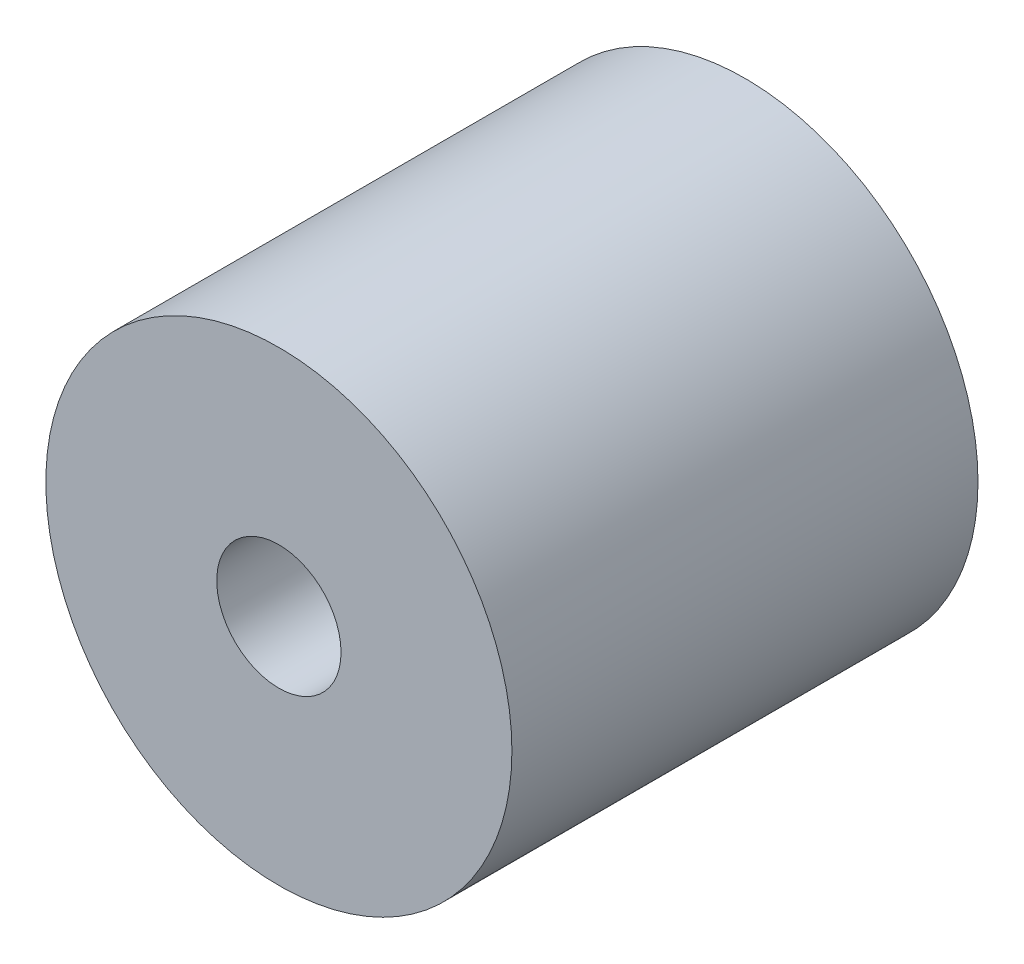
from build123d import *

# Parameters (mm, degrees)
CROQUIS1_R              = 150
CROQUIS1_R_2            = 40
SALIENTE_EXTRUIR1_DEPTH = 300


with BuildPart() as part:
    # Croquis1 → Saliente-Extruir1 (new body)
    with BuildSketch(Plane.XY):
        Circle(CROQUIS1_R)
        Circle(CROQUIS1_R_2, mode=Mode.SUBTRACT)
    extrude(amount=SALIENTE_EXTRUIR1_DEPTH)


solid = part.part
